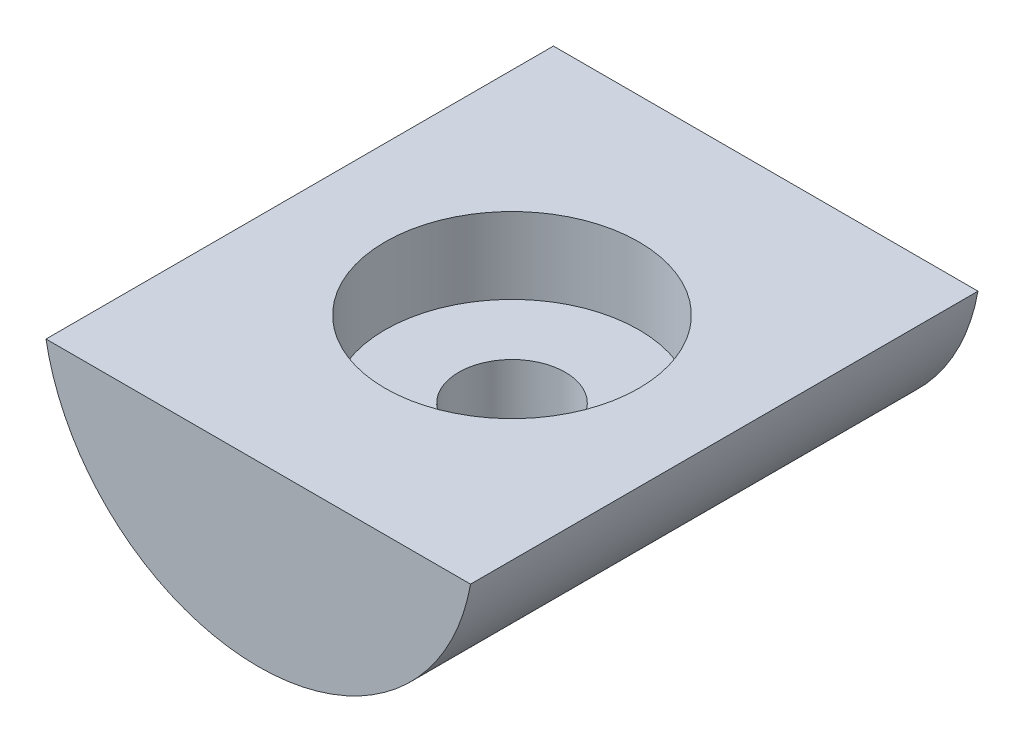
from build123d import *

# Parameters (mm, degrees)
BOSS_EXTRUDE1_DEPTH = 20
SKETCH2_R           = 2.1
CUT_EXTRUDE1_DEPTH  = 8
SKETCH3_R           = 5
CUT_EXTRUDE2_DEPTH  = 3


with BuildPart() as part:
    # Sketch1 → Boss-Extrude1 (new body)
    with BuildSketch(Plane.XY):
        with BuildLine():
            Line((-8.366600265, -1.5), (8.366600265, -1.5))
            ThreePointArc((8.366600265, -1.5), (0, -8.5), (-8.366600265, -1.5))
        make_face()
    extrude(amount=BOSS_EXTRUDE1_DEPTH)

    # Sketch2 → Cut-Extrude1 (cut, through all)
    with BuildSketch(Plane(origin=(0, -1.5, 0), x_dir=(1, 0, 0), z_dir=(0, 1, 0))):
        with Locations((0, -10)):
            Circle(SKETCH2_R)
    extrude(amount=-CUT_EXTRUDE1_DEPTH, mode=Mode.SUBTRACT)

    # Sketch3 → Cut-Extrude2 (cut)
    with BuildSketch(Plane(origin=(0, -1.5, 0), x_dir=(1, 0, 0), z_dir=(0, 1, 0))):
        with Locations((0, -10)):
            Circle(SKETCH3_R)
    extrude(amount=-CUT_EXTRUDE2_DEPTH, mode=Mode.SUBTRACT)


solid = part.part
